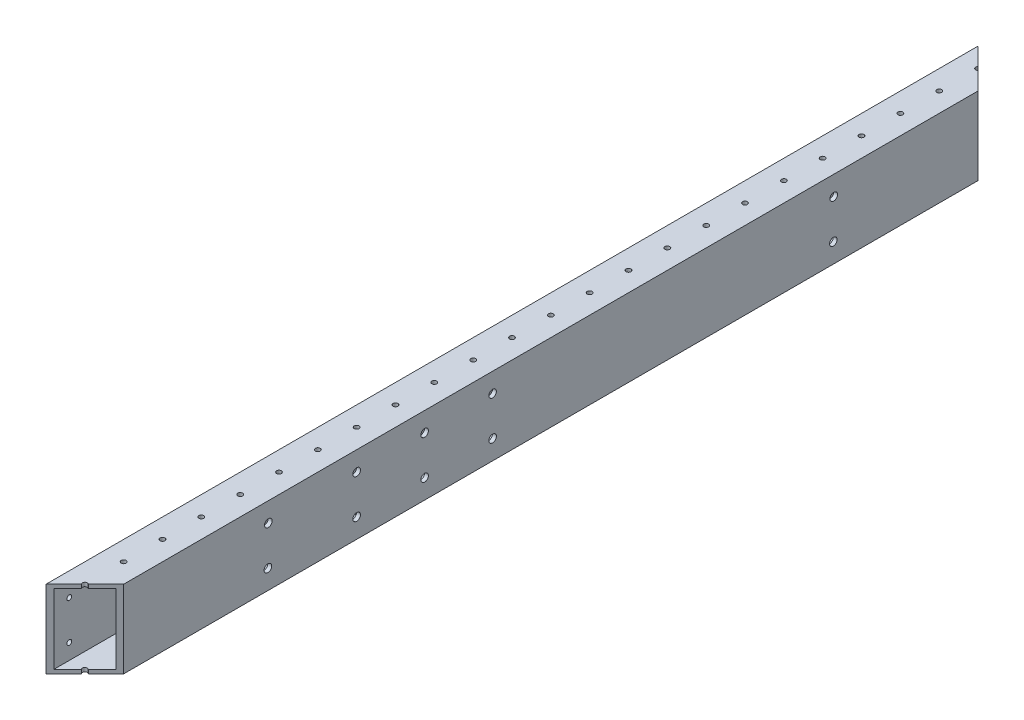
from build123d import *

# Parameters (mm, degrees)
SKETCH1_W           = 25.4
SKETCH1_H           = 50.8
SKETCH1_W_2         = 20.32
SKETCH1_H_2         = 45.72
EXTRUDE_THIN1_DEPTH = 609.6
SKETCH2_R           = 1.5875
CUT_EXTRUDE1_DEPTH  = 51.8
LPATTERN1_COUNT     = 50
LPATTERN1_PITCH     = 25.4
CUT_EXTRUDE2_DEPTH  = 51.8
SKETCH5_R           = 1.5875
CUT_EXTRUDE3_DEPTH  = 26.4
SKETCH7_R           = 2.4892
CUT_EXTRUDE4_DEPTH  = 26.4


with BuildPart() as part:
    # Sketch1 → Extrude-Thin1 (new body)
    with BuildSketch(Plane.XY):
        with Locations((12.7, 25.4)):
            Rectangle(SKETCH1_W, SKETCH1_H)
        with Locations((12.7, 25.4)):
            Rectangle(SKETCH1_W_2, SKETCH1_H_2, mode=Mode.SUBTRACT)
    extrude(amount=EXTRUDE_THIN1_DEPTH)

    # Sketch2 → Cut-Extrude1 (cut, through all)
    with BuildSketch(Plane(origin=(0, 50.8, 0), x_dir=(1, 0, 0), z_dir=(0, 1, 0))):
        with Locations((12.7, -596.9)):
            Circle(SKETCH2_R)
    cut_extrude1 = extrude(amount=-CUT_EXTRUDE1_DEPTH, mode=Mode.SUBTRACT)

    # LPattern1: Cut-Extrude1 ×50
    with Locations(*[(0, 0, -i * LPATTERN1_PITCH) for i in range(1, LPATTERN1_COUNT)]):
        add(cut_extrude1, mode=Mode.SUBTRACT)

    # Sketch4 → Cut-Extrude2 (cut, through all)
    with BuildSketch(Plane(origin=(0, 50.8, 0), x_dir=(1, 0, 0), z_dir=(0, 1, 0))):
        Polygon((0, -609.6), (25.4, -584.2), (25.4, -609.6), align=None)
        Polygon((0, 0), (25.4, 0), (25.4, -25.4), align=None)
    extrude(amount=-CUT_EXTRUDE2_DEPTH, mode=Mode.SUBTRACT)

    # Sketch5 → Cut-Extrude3 (cut, through all)
    with BuildSketch(Plane.ZY):
        with Locations((12.7, 12.7)):
            Circle(SKETCH5_R)
        with Locations((12.7, 38.1)):
            Circle(SKETCH5_R)
        with Locations((596.9, 38.1)):
            Circle(SKETCH5_R)
        with Locations((596.9, 12.7)):
            Circle(SKETCH5_R)
    extrude(amount=-CUT_EXTRUDE3_DEPTH, mode=Mode.SUBTRACT)

    # Sketch7 → Cut-Extrude4 (cut, through all)
    with BuildSketch(Plane.ZY):
        with Locations((489.585, 38.1)):
            Circle(SKETCH7_R)
        with Locations((489.845193373, 12.7)):
            Circle(SKETCH7_R)
        with Locations((120.015, 12.7)):
            Circle(SKETCH7_R)
        with Locations((119.754806627, 38.1)):
            Circle(SKETCH7_R)
        with Locations((342.9, 38.1)):
            Circle(SKETCH7_R)
        with Locations((342.9, 12.7)):
            Circle(SKETCH7_R)
        with Locations((387.35, 12.7)):
            Circle(SKETCH7_R)
        with Locations((387.35, 38.1)):
            Circle(SKETCH7_R)
        with Locations((431.8, 38.1)):
            Circle(SKETCH7_R)
        with Locations((431.8, 12.7)):
            Circle(SKETCH7_R)
    extrude(amount=-CUT_EXTRUDE4_DEPTH, mode=Mode.SUBTRACT)


solid = part.part
